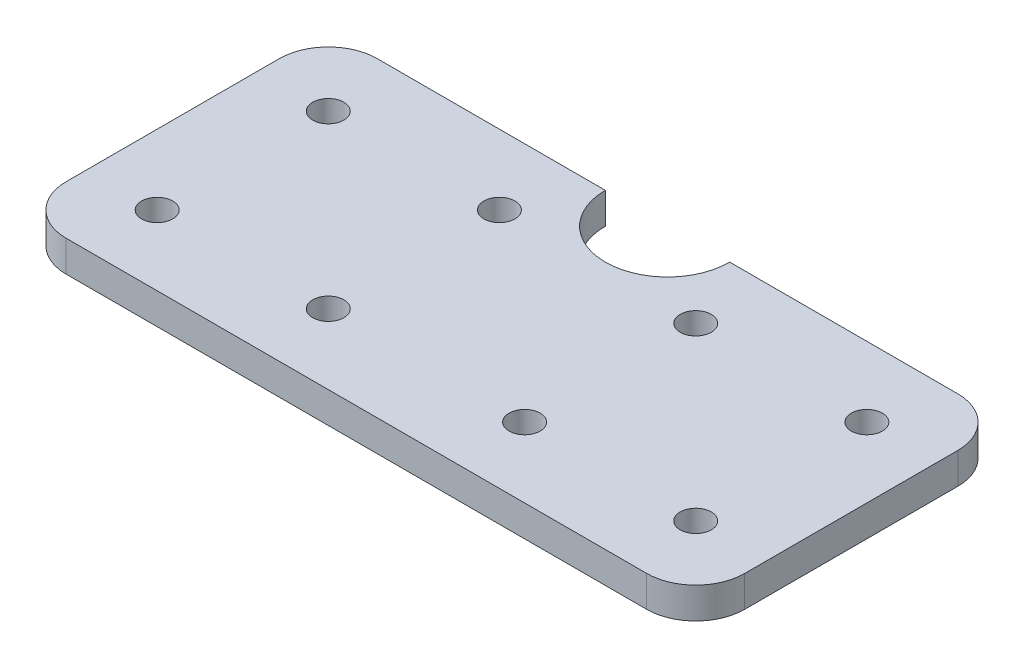
from build123d import *

# Parameters (mm, degrees)
SKETCH1_W           = 138.5
SKETCH1_H           = 63.5
BOSS_EXTRUDE1_DEPTH = 6.35
SKETCH2_R           = 3.175
CUT_EXTRUDE1_DEPTH  = 6.35
FILLET1_R           = 10
CUT_EXTRUDE4_DEPTH  = 6.35


with BuildPart() as part:
    # Sketch1 → Boss-Extrude1 (new body)
    with BuildSketch(Plane(origin=(0, 0, 0), x_dir=(1, 0, 0), z_dir=(0, 1, 0))):
        Rectangle(SKETCH1_W, SKETCH1_H)
    extrude(amount=BOSS_EXTRUDE1_DEPTH)

    # Sketch2 → Cut-Extrude1 (cut)
    with BuildSketch(Plane(origin=(0, 6.35, 0), x_dir=(1, 0, 0), z_dir=(0, 1, 0))):
        with Locations((-54.9625, 17.4625)):
            Circle(SKETCH2_R)
        with Locations((-20.0375, 17.4625)):
            Circle(SKETCH2_R)
        with Locations((20.0375, 17.4625)):
            Circle(SKETCH2_R)
        with Locations((54.9625, 17.4625)):
            Circle(SKETCH2_R)
        with Locations((54.9625, -17.4625)):
            Circle(SKETCH2_R)
        with Locations((20.0375, -17.4625)):
            Circle(SKETCH2_R)
        with Locations((-20.0375, -17.4625)):
            Circle(SKETCH2_R)
        with Locations((-54.9625, -17.4625)):
            Circle(SKETCH2_R)
    extrude(amount=-CUT_EXTRUDE1_DEPTH, mode=Mode.SUBTRACT)

    # Fillet1
    fillet1_edges = [part.edges().sort_by_distance(p)[0] for p in [
        (69.25, 3.175, 31.75),
        (-69.25, 3.175, 31.75),
        (-69.25, 3.175, -31.75),
        (69.25, 3.175, -31.75),
    ]]
    fillet(fillet1_edges, radius=FILLET1_R)

    # Sketch3 → Cut-Extrude4 (cut)
    with BuildSketch(Plane(origin=(0, 6.35, 0), x_dir=(1, 0, 0), z_dir=(0, 1, 0))):
        with BuildLine():
            Line((-12.7, 31.75), (12.7, 31.75))
            ThreePointArc((12.7, 31.75), (0, 19.05), (-12.7, 31.75))
        make_face()
    extrude(amount=-CUT_EXTRUDE4_DEPTH, mode=Mode.SUBTRACT)


solid = part.part
